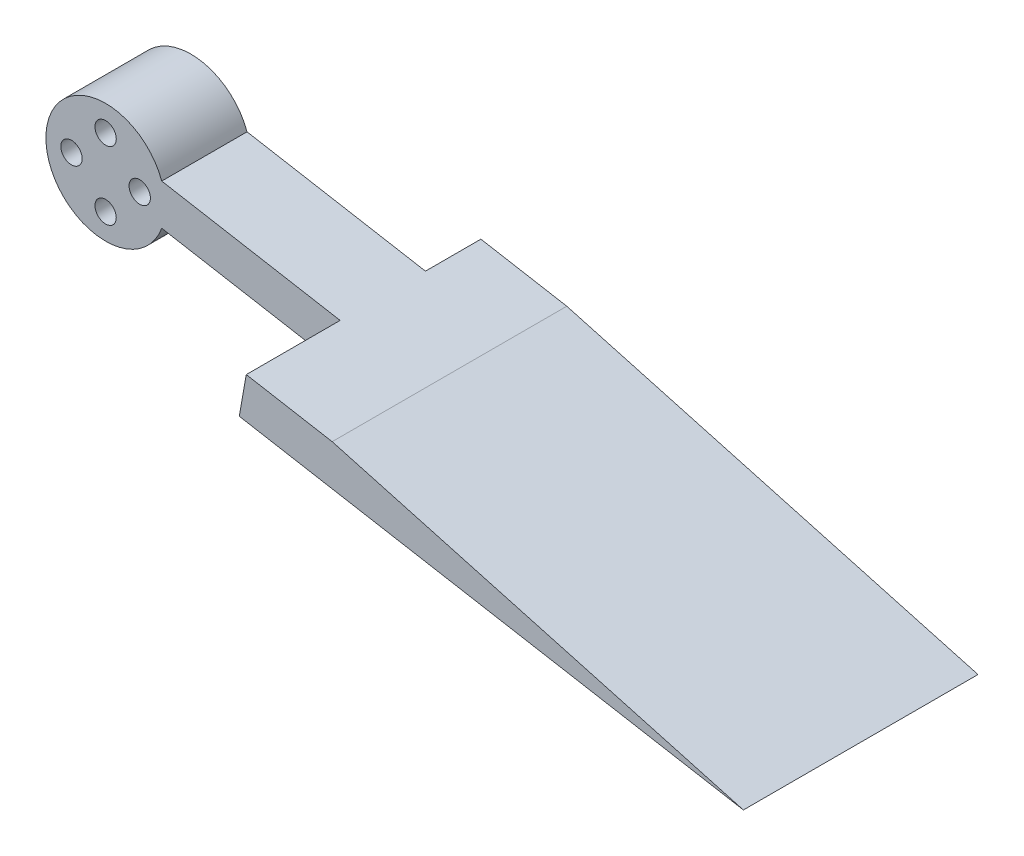
from build123d import *

# Parameters (mm, degrees)
EXTRUDE_1_DEPTH      = 10
EXTRUDE_2_DEPTH      = 11
EXTRUDE_2_DEPTH_BACK = 16.5
CUT_EXTRUDE_1_DEPTH  = 28.5
HOLE_WIZARD_M3_1_D   = 2.5


with BuildPart() as part:
    # 스케치1 → 보스-돌출1 (new body)
    with BuildSketch(Plane.XY):
        with BuildLine():
            Line((6.577848346, 2.394141003), (86.577848346, -11.712017453))
            Line((86.577848346, -11.712017453), (85.759003896, -16.355915091))
            Line((85.759003896, -16.355915091), (6.577848346, -2.394141003))
            ThreePointArc((6.577848346, -2.394141003), (-7, 0), (6.577848346, 2.394141003))
        make_face()
    extrude(amount=EXTRUDE_1_DEPTH)

    # 스케치2 → 보스-돌출2 (add, two sides)
    with BuildSketch(Plane.XY.offset(10)) as extrude_2_sk:
        Polygon((86.577848346, -11.712017453), (27.489383165, -1.293126793), (26.670538716, -5.937024431), (85.759003896, -16.355915091), align=None)
    extrude(amount=EXTRUDE_2_DEPTH)
    extrude(extrude_2_sk.sketch, amount=-EXTRUDE_2_DEPTH_BACK)

    # 스케치4 → 컷-돌출1 (cut, through all)
    with BuildSketch(Plane.XY.offset(21)):
        Polygon((86.577848346, -11.712017453), (85.759003896, -16.355915091), (37.556934536, -3.06830773), align=None)
    extrude(amount=-CUT_EXTRUDE_1_DEPTH, mode=Mode.SUBTRACT)

    # M3 나사 구멍1 (through all)
    with Locations(Plane.XY.offset(10)):
        with Locations((-4, 0), (0, 4), (4, 0), (0, -4)):
            Hole(HOLE_WIZARD_M3_1_D / 2)


solid = part.part
